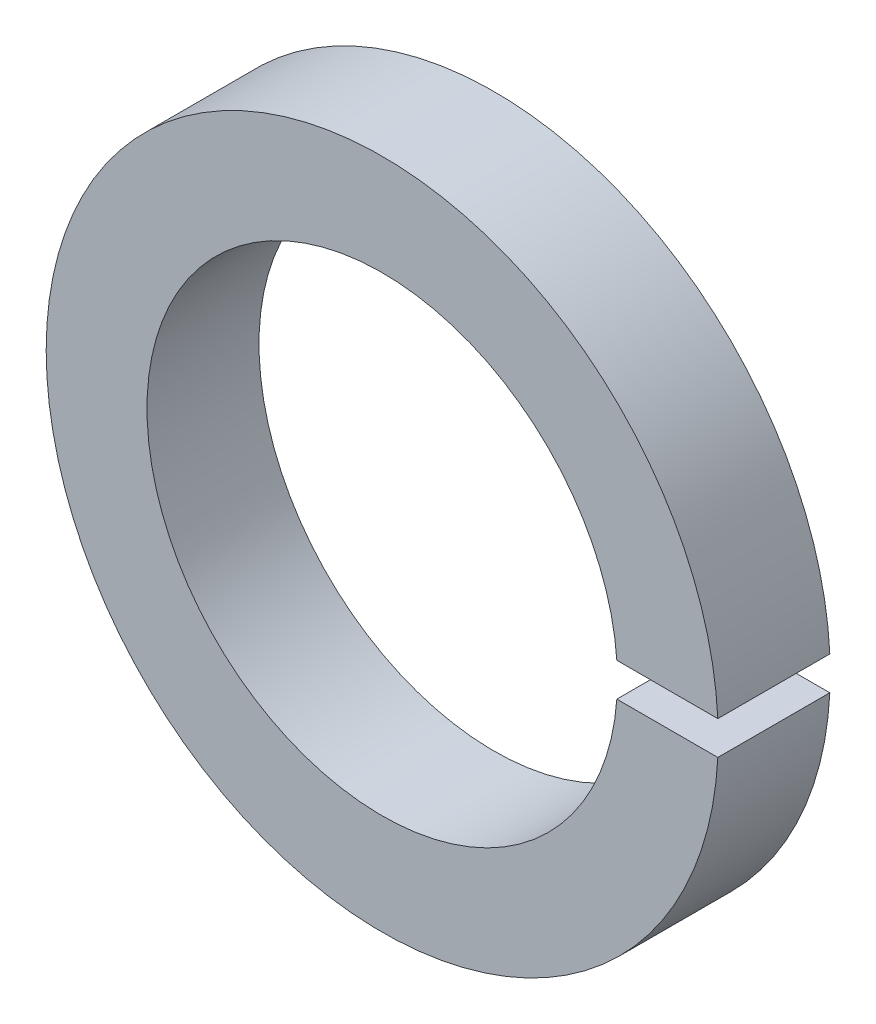
from build123d import *

# Parameters (mm, degrees)
SKETCH1_R           = 15
SKETCH1_R_2         = 10.5
BOSS_EXTRUDE1_DEPTH = 5
SKETCH3_W           = 5.868201952
SKETCH3_H           = 1.5
CUT_EXTRUDE1_DEPTH  = 6


with BuildPart() as part:
    # Sketch1 → Boss-Extrude1 (new body)
    with BuildSketch(Plane.XY):
        Circle(SKETCH1_R)
        Circle(SKETCH1_R_2, mode=Mode.SUBTRACT)
    extrude(amount=BOSS_EXTRUDE1_DEPTH)

    # Sketch3 → Cut-Extrude1 (cut, through all)
    with BuildSketch(Plane(origin=(0, 0, 0), x_dir=(-1, 0, 0), z_dir=(0, 0, -1))):
        with Locations((-12.629297394, 0)):
            Rectangle(SKETCH3_W, SKETCH3_H)
    extrude(amount=-CUT_EXTRUDE1_DEPTH, mode=Mode.SUBTRACT)


solid = part.part
